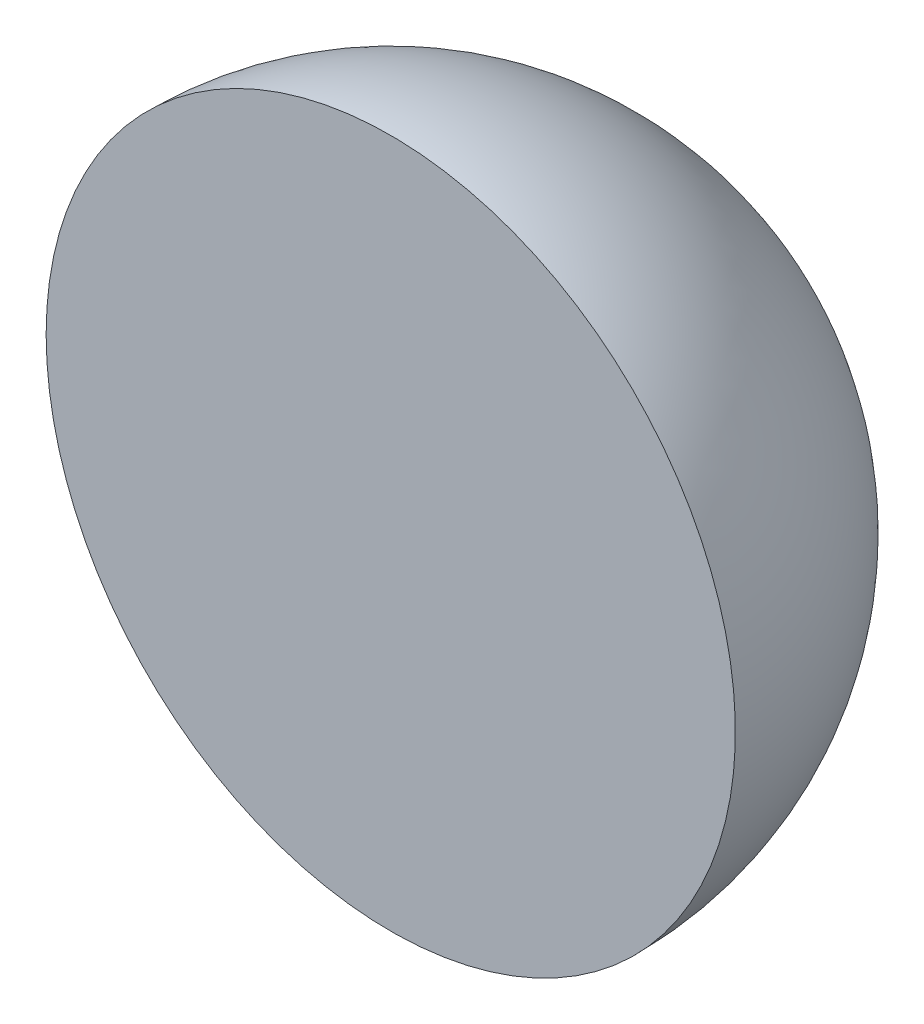
from build123d import *

# Parameters (mm, degrees)
REVOLVE1_ANGLE = 180


with BuildPart() as part:
    # Sketch1 → Revolve1 (revolve)
    with BuildSketch(Plane.XY):
        with BuildLine():
            Line((0, 50), (0, -50))
            ThreePointArc((0, -50), (-50, 0), (0, 50))
        make_face()
    revolve(axis=Axis((0, 50, 0), (0, -1, 0)), revolution_arc=REVOLVE1_ANGLE)


solid = part.part
